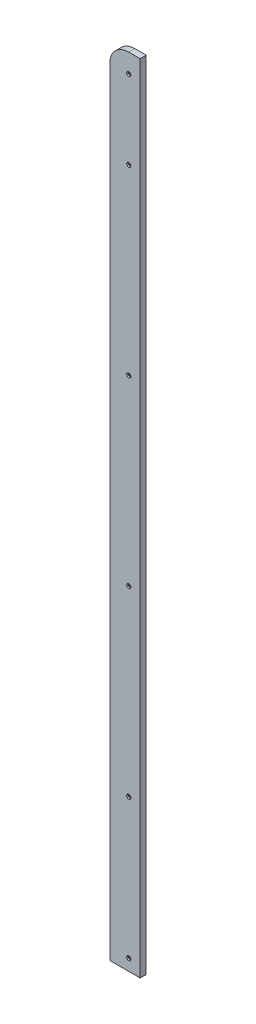
from build123d import *

# Parameters (mm, degrees)
BOSS_EXTRU_1_DEPTH                                 = 8
CHAMBRAGE_POUR_VIS_T_TE_CYLINDRIQUE_CO_D           = 3
CHAMBRAGE_POUR_VIS_T_TE_CYLINDRIQUE_CO_CBORE_D     = 5.5
CHAMBRAGE_POUR_VIS_T_TE_CYLINDRIQUE_CO_CBORE_DEPTH = 2


with BuildPart() as part:
    # Esquisse1 → Boss.-Extru.1 (new body)
    with BuildSketch(Plane.XY):
        with BuildLine():
            Line((201, 18.5), (186, 18.5))
            ThreePointArc((186, 18.5), (168.32233047, 11.17766953), (161, -6.5))
            Line((161, -6.5), (161, -1029))
            Line((161, -1029), (201, -1029))
            Line((201, -1029), (201, 18.5))
        make_face()
    extrude(amount=BOSS_EXTRU_1_DEPTH)

    # Chambrage pour vis à tête cylindrique courte six pans creux M31 (through all)
    with Locations(Plane.XY.offset(8)):
        with Locations((186, -1014), (186, -830), (186, -590), (186, -350), (186, -110), (186, -6.5)):
            CounterBoreHole(CHAMBRAGE_POUR_VIS_T_TE_CYLINDRIQUE_CO_D / 2, CHAMBRAGE_POUR_VIS_T_TE_CYLINDRIQUE_CO_CBORE_D / 2, CHAMBRAGE_POUR_VIS_T_TE_CYLINDRIQUE_CO_CBORE_DEPTH)


solid = part.part
